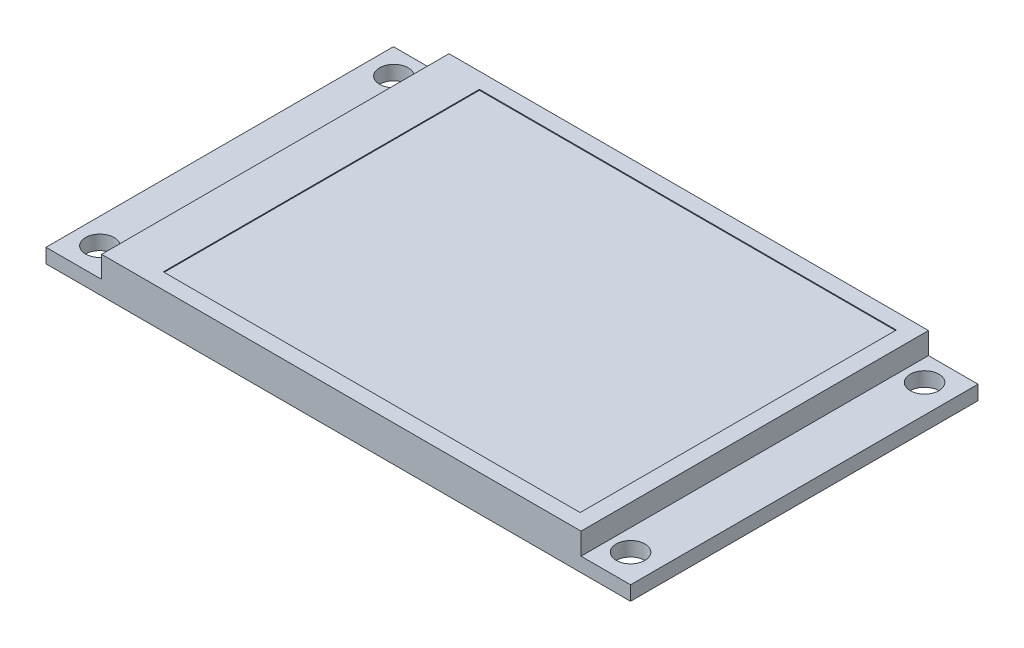
from build123d import *

# Parameters (mm, degrees)
SKETCH1_W           = 67.3
SKETCH1_H           = 40
SKETCH1_R           = 1.65
BOSS_EXTRUDE1_DEPTH = 1.65
SKETCH2_W           = 55.2
SKETCH2_H           = 40
BOSS_EXTRUDE2_DEPTH = 2.5
SKETCH3_W           = 48
SKETCH3_H           = 36.4
CUT_EXTRUDE1_DEPTH  = 0.1


with BuildPart() as part:
    # Sketch1 → Boss-Extrude1 (new body)
    with BuildSketch(Plane(origin=(0, 0, 0), x_dir=(1, 0, 0), z_dir=(0, 1, 0))):
        Rectangle(SKETCH1_W, SKETCH1_H)
        with Locations(Location((-30.7, 17.1, 0), (0, 0, 270))):  # turned: the seam where the file's is
            Circle(SKETCH1_R, mode=Mode.SUBTRACT)
        with Locations(Location((-30.7, -16.75, 0), (0, 0, 270))):  # turned: the seam where the file's is
            Circle(SKETCH1_R, mode=Mode.SUBTRACT)
        with Locations(Location((30.4, -16.75, 0), (0, 0, 270))):  # turned: the seam where the file's is
            Circle(SKETCH1_R, mode=Mode.SUBTRACT)
        with Locations(Location((30.4, 17.1, 0), (0, 0, 270))):  # turned: the seam where the file's is
            Circle(SKETCH1_R, mode=Mode.SUBTRACT)
    extrude(amount=BOSS_EXTRUDE1_DEPTH)

    # Sketch2 → Boss-Extrude2 (add)
    with BuildSketch(Plane(origin=(0, 1.65, 0), x_dir=(1, 0, 0), z_dir=(0, 1, 0))):
        with Locations((0.35, 0)):
            Rectangle(SKETCH2_W, SKETCH2_H)
    extrude(amount=BOSS_EXTRUDE2_DEPTH)

    # Sketch3 → Cut-Extrude1 (cut)
    with BuildSketch(Plane(origin=(0, 4.15, 0), x_dir=(1, 0, 0), z_dir=(0, 1, 0))):
        with Locations((2.05, 0)):
            Rectangle(SKETCH3_W, SKETCH3_H)
    extrude(amount=-CUT_EXTRUDE1_DEPTH, mode=Mode.SUBTRACT)


solid = part.part
